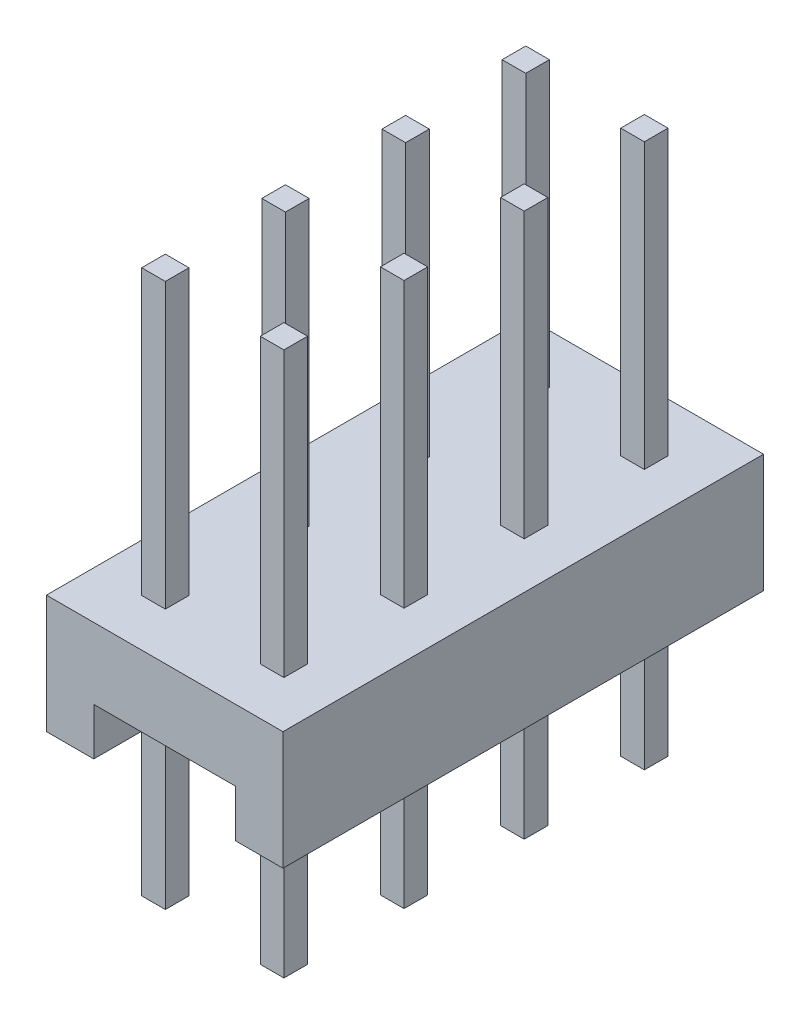
from build123d import *

# Parameters (mm, degrees)
EXTRUDE_1_DEPTH        = 2.54
EXTRUDE_START          = -5.5
SKETCH_2_W             = 0.5
SKETCH_2_H             = 0.5
EXTRUDE_2_DEPTH        = 11.5
PATTERN_LINEAR_1_COUNT = 4
PATTERN_LINEAR_1_PITCH = 2.54


with BuildPart() as part:
    # Эскиз1 → Бобышка-Вытянуть1 (new body)
    with BuildSketch(Plane.XY):
        Polygon((-2.5, 0), (-2.5, 2.5), (2.5, 2.5), (2.5, 0), (1.5, 0), (1.5, 1), (-1.5, 1), (-1.5, 0), align=None)
    extrude_1 = extrude(amount=EXTRUDE_1_DEPTH)

    # Эскиз2 → Бобышка-Вытянуть2 (add)
    with BuildSketch(Plane(origin=(0, 2.5, 0), x_dir=(1, 0, 0), z_dir=(0, 1, 0)).offset(EXTRUDE_START)):
        with Locations((-1.236880281, -1.29)):
            Rectangle(SKETCH_2_W, SKETCH_2_H)
        with Locations((1.27, -1.29)):
            Rectangle(SKETCH_2_W, SKETCH_2_H)
    extrude_2 = extrude(amount=EXTRUDE_2_DEPTH)

    # Линейный массив1: Бобышка-Вытянуть1, Бобышка-Вытянуть2 ×4
    with Locations(*[(0, 0, -i * PATTERN_LINEAR_1_PITCH) for i in range(1, PATTERN_LINEAR_1_COUNT)]):
        add(extrude_1)
        add(extrude_2)


solid = part.part
